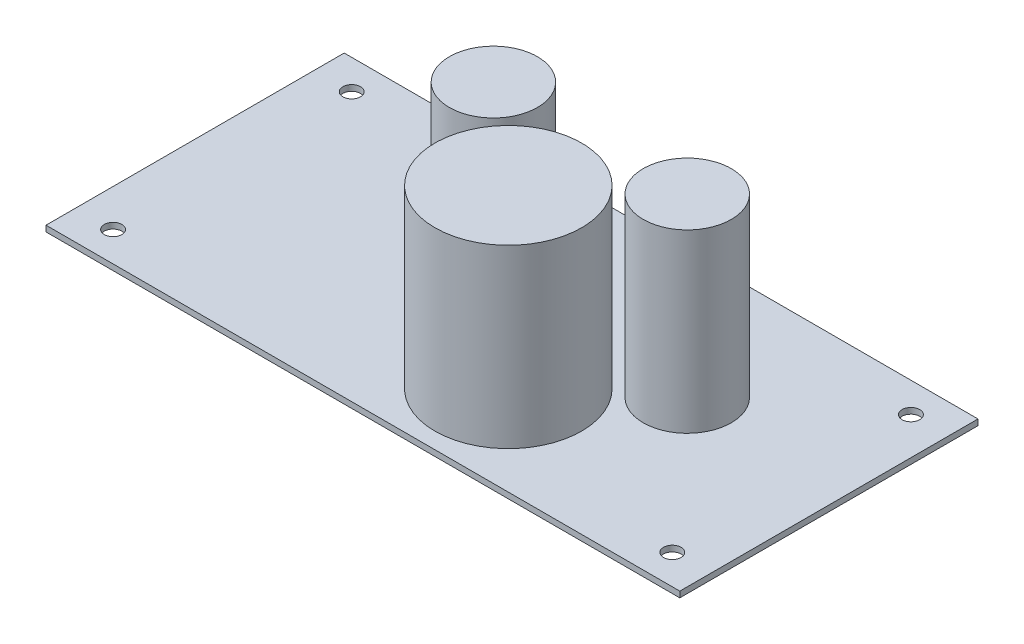
from build123d import *

# Parameters (mm, degrees)
SCHIZZO1_W                   = 107.95
SCHIZZO1_H                   = 50.79
ESTRUSIONE_ESTRUSIONE1_DEPTH = 1
SCHIZZO2_R                   = 1.5
TAGLIO_ESTRUSIONE1_DEPTH     = 2
SCHIZZO3_R                   = 7.5
SCHIZZO3_R_2                 = 12.5
ESTRUSIONE_ESTRUSIONE2_DEPTH = 30


with BuildPart() as part:
    # Schizzo1 → Estrusione-Estrusione1 (new body)
    with BuildSketch(Plane(origin=(0, 0, 0), x_dir=(1, 0, 0), z_dir=(0, 1, 0))):
        Rectangle(SCHIZZO1_W, SCHIZZO1_H)
    extrude(amount=ESTRUSIONE_ESTRUSIONE1_DEPTH)

    # Schizzo2 → Taglio-Estrusione1 (cut, through all)
    with BuildSketch(Plane(origin=(0, 1, 0), x_dir=(1, 0, 0), z_dir=(0, 1, 0))):
        with Locations((-47.625, 20.32)):
            Circle(SCHIZZO2_R)
        with Locations((47.625, 20.32)):
            Circle(SCHIZZO2_R)
        with Locations((47.625, -20.32)):
            Circle(SCHIZZO2_R)
        with Locations((-47.625, -20.32)):
            Circle(SCHIZZO2_R)
    extrude(amount=-TAGLIO_ESTRUSIONE1_DEPTH, mode=Mode.SUBTRACT)

    # Schizzo3 → Estrusione-Estrusione2 (add)
    with BuildSketch(Plane(origin=(0, 1, 0), x_dir=(1, 0, 0), z_dir=(0, 1, 0))):
        with Locations((26.035, 3.815)):
            Circle(SCHIZZO3_R)
        with Locations((-6.985, 3.815)):
            Circle(SCHIZZO3_R)
        with Locations((9.525, -10.155)):
            Circle(SCHIZZO3_R_2)
    extrude(amount=ESTRUSIONE_ESTRUSIONE2_DEPTH)


solid = part.part
